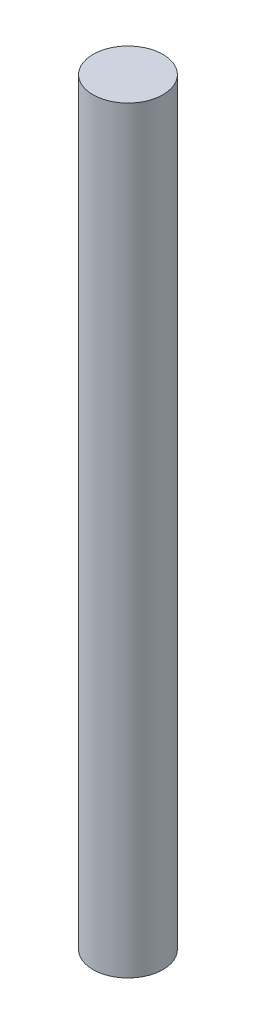
from build123d import *

# Parameters (mm, degrees)
SKETCH1_R           = 3
BOSS_EXTRUDE1_DEPTH = 65


with BuildPart() as part:
    # Sketch1 → Boss-Extrude1 (new body)
    with BuildSketch(Plane(origin=(0, 0, 0), x_dir=(1, 0, 0), z_dir=(0, 1, 0))):
        with Locations(Location((0, 0, 0), (0, 0, 270))):  # turned: the seam where the file's is
            Circle(SKETCH1_R)
    extrude(amount=BOSS_EXTRUDE1_DEPTH)


solid = part.part
